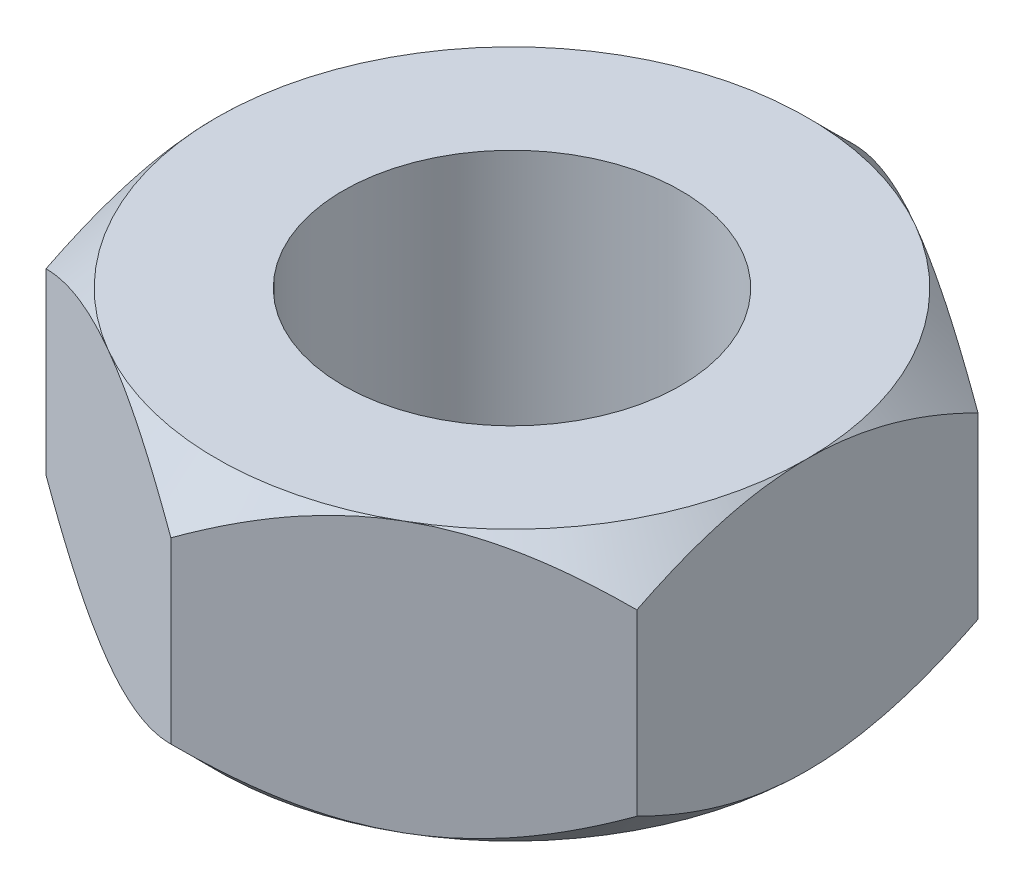
from build123d import *

# Parameters (mm, degrees)
SKETCH1_R           = 2
BOSS_EXTRUDE1_DEPTH = 3.2
SKETCH2_OUTSIDE_W   = 19.632
SKETCH2_OUTSIDE_H   = 20.714
SKETCH2_OUTSIDE_R   = 3.5
CUT_EXTRUDE1_DEPTH  = 4.2
CUT_EXTRUDE1_TAPER  = 45
SKETCH3_OUTSIDE_W   = 19.632
SKETCH3_OUTSIDE_H   = 20.714
SKETCH3_OUTSIDE_R   = 3.5
CUT_EXTRUDE2_DEPTH  = 4.2
CUT_EXTRUDE2_TAPER  = 45


with BuildPart() as part:
    # Sketch1 → Boss-Extrude1 (new body)
    with BuildSketch(Plane(origin=(0, 0, 0), x_dir=(1, 0, 0), z_dir=(0, 1, 0))):
        Polygon((0, 4.041451884), (-3.5, 2.020725942), (-3.5, -2.020725942), (0, -4.041451884), (3.5, -2.020725942), (3.5, 2.020725942), align=None)
        Circle(SKETCH1_R, mode=Mode.SUBTRACT)
    extrude(amount=BOSS_EXTRUDE1_DEPTH)

    # Sketch2 outside → Cut-Extrude1 (cut, through all)
    with BuildSketch(Plane(origin=(0, 3.2, 0), x_dir=(1, 0, 0), z_dir=(0, 1, 0))):
        Rectangle(SKETCH2_OUTSIDE_W, SKETCH2_OUTSIDE_H)
        Circle(SKETCH2_OUTSIDE_R, mode=Mode.SUBTRACT)
    extrude(amount=-CUT_EXTRUDE1_DEPTH, taper=CUT_EXTRUDE1_TAPER, mode=Mode.SUBTRACT)

    # Sketch3 outside → Cut-Extrude2 (cut, through all)
    with BuildSketch(Plane.XZ):
        Rectangle(SKETCH3_OUTSIDE_W, SKETCH3_OUTSIDE_H)
        Circle(SKETCH3_OUTSIDE_R, mode=Mode.SUBTRACT)
    extrude(amount=-CUT_EXTRUDE2_DEPTH, taper=CUT_EXTRUDE2_TAPER, mode=Mode.SUBTRACT)


solid = part.part
